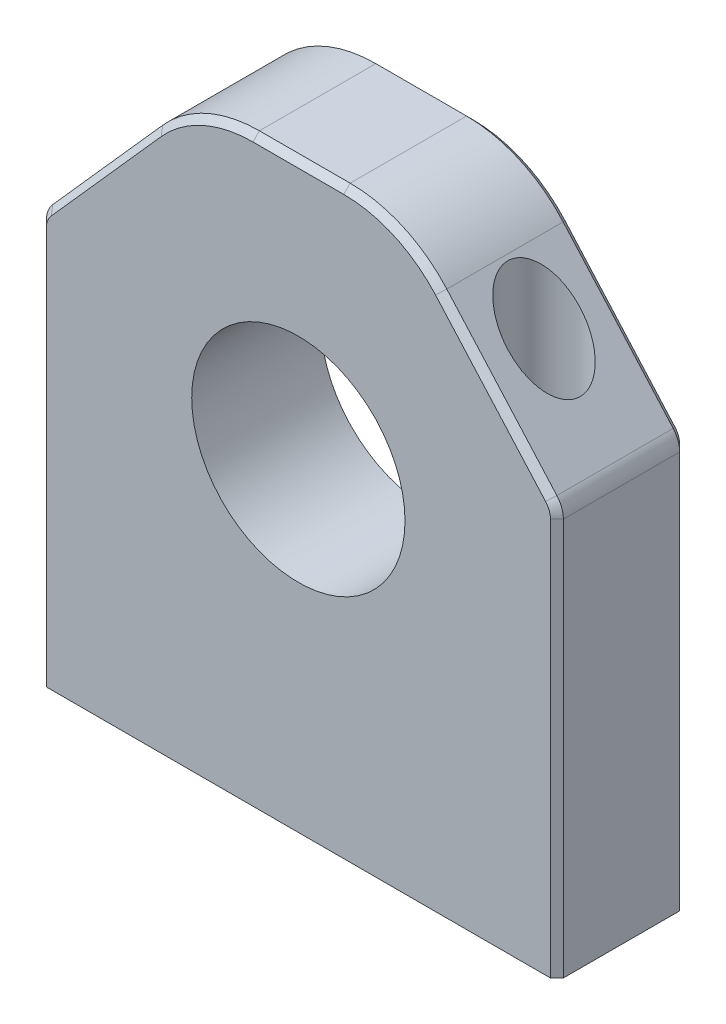
from build123d import *

# Parameters (mm, degrees)
SKETCH1_R            = 8.25
BOSS_EXTRUDE1_DEPTH  = 10
M3_CLEARANCE_HOLE1_D = 3.4
SKETCH2_R            = 2.8
CUT_EXTRUDE1_DEPTH   = 35
FILLET1_R            = 10
FILLET2_R            = 2
CHAMFER1_SIZE        = 0.5


with BuildPart() as part:
    # Sketch1 → Boss-Extrude1 (new body)
    with BuildSketch(Plane.XY):
        Polygon((8, 45), (-8, 45), (-20, 31.5), (-20, 0), (20, 0), (20, 31.5), align=None)
        with Locations((0, 25)):
            Circle(SKETCH1_R, mode=Mode.SUBTRACT)
    extrude(amount=BOSS_EXTRUDE1_DEPTH)

    # M3 Clearance Hole1 (through all)
    with Locations(Plane(origin=(-14, 45, 5), x_dir=(0, 0, 1), z_dir=(0, 1, 0))):
        with Locations((0, 0), (0, 28)):
            Hole(M3_CLEARANCE_HOLE1_D / 2)

    # Sketch2 → Cut-Extrude1 (cut)
    with BuildSketch(Plane(origin=(0, 45, 0), x_dir=(1, 0, 0), z_dir=(0, 1, 0))):
        with Locations((14, -5)):
            Circle(SKETCH2_R)
        with Locations((-14, -5)):
            Circle(SKETCH2_R)
    extrude(amount=-CUT_EXTRUDE1_DEPTH, mode=Mode.SUBTRACT)

    # Fillet1
    fillet1_edges = [part.edges().sort_by_distance(p)[0] for p in [
        (-8, 45, 5),
        (8, 45, 5),
    ]]
    fillet(fillet1_edges, radius=FILLET1_R)

    # Fillet2
    fillet2_edges = [part.edges().sort_by_distance(p)[0] for p in [
        (-20, 31.5, 5),
        (20, 31.5, 5),
    ]]
    fillet(fillet2_edges, radius=FILLET2_R)

    # Chamfer1
    chamfer1_edges = [part.edges().sort_by_distance(p)[0] for p in [
        (-15.239125591, 36.855983711, 0),
        (-15.239125591, 36.855983711, 10),
        (0, 45, 0),
        (15.239125591, 36.855983711, 0),
        (7.605899873, 44.122400558, 0),
        (-7.605899873, 44.122400558, 0),
        (0, 45, 10),
        (15.239125591, 36.855983711, 10),
        (7.605899873, 44.122400558, 10),
        (-7.605899873, 44.122400558, 10),
        (-20, 15.369800678, 0),
        (-20, 15.369800678, 10),
        (20, 15.369800678, 0),
        (19.869443403, 31.45036247, 0),
        (-19.869443403, 31.45036247, 0),
        (20, 15.369800678, 10),
        (19.869443403, 31.45036247, 10),
        (-19.869443403, 31.45036247, 10),
    ]]
    chamfer(chamfer1_edges, length=CHAMFER1_SIZE)


solid = part.part
